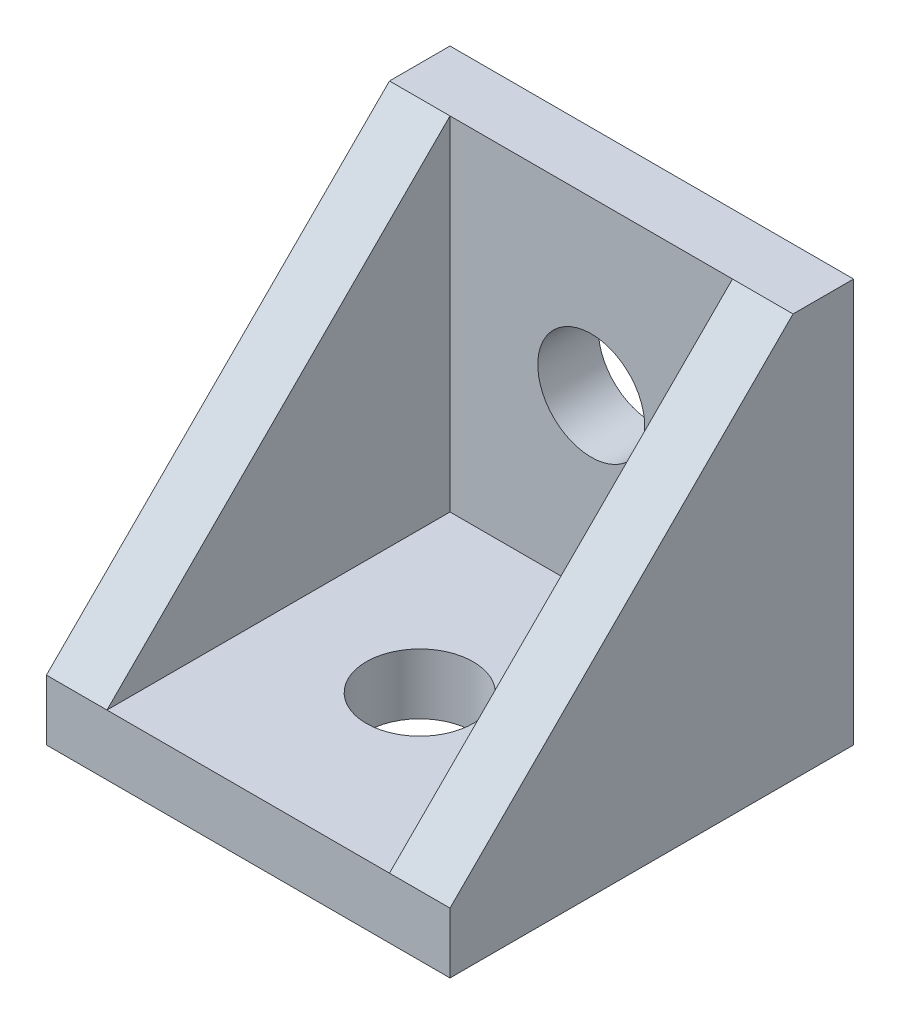
from build123d import *

# Parameters (mm, degrees)
ESBO_O1_W                = 20
ESBO_O1_H                = 20
RESSALTO_EXTRUS_O1_DEPTH = 20
CORTE_EXTRUS_O1_DEPTH    = 21
ESBO_O3_W                = 14
ESBO_O3_H                = 17
CORTE_EXTRUS_O2_DEPTH    = 17
ESBO_O4_W                = 6
ESBO_O4_H                = 6
RESSALTO_EXTRUS_O2_DEPTH = 2
ESBO_O5_W                = 6
ESBO_O5_H                = 6
RESSALTO_EXTRUS_O3_DEPTH = 2
ESBO_O6_R                = 2.65
CORTE_EXTRUS_O3_DEPTH    = 6
ESBO_O7_R                = 2.65
CORTE_EXTRUS_O4_DEPTH    = 6


with BuildPart() as part:
    # Esboço1 → Ressalto-extrusão1 (new body)
    with BuildSketch(Plane.XY):
        with Locations((10, 10)):
            Rectangle(ESBO_O1_W, ESBO_O1_H)
    extrude(amount=RESSALTO_EXTRUS_O1_DEPTH)

    # Esboço2 → Corte-extrusão1 (cut, through all)
    with BuildSketch(Plane(origin=(20, 0, 0), x_dir=(0, 0, -1), z_dir=(1, 0, 0))):
        Polygon((-3, 20), (-20, 3), (-20, 20), align=None)
    extrude(amount=-CORTE_EXTRUS_O1_DEPTH, mode=Mode.SUBTRACT)

    # Esboço3 → Corte-extrusão2 (cut)
    with BuildSketch(Plane.XY.offset(20)):
        with Locations((10, 11.5)):
            Rectangle(ESBO_O3_W, ESBO_O3_H)
    extrude(amount=-CORTE_EXTRUS_O2_DEPTH, mode=Mode.SUBTRACT)

    # Esboço4 → Ressalto-extrusão2 (add)
    with BuildSketch(Plane(origin=(0, 0, 0), x_dir=(-1, 0, 0), z_dir=(0, 0, -1))):
        with Locations((-10, 3)):
            Rectangle(ESBO_O4_W, ESBO_O4_H)
    extrude(amount=RESSALTO_EXTRUS_O2_DEPTH)

    # Esboço5 → Ressalto-extrusão3 (add)
    with BuildSketch(Plane.XZ):
        with Locations((10, 3)):
            Rectangle(ESBO_O5_W, ESBO_O5_H)
    extrude(amount=RESSALTO_EXTRUS_O3_DEPTH)

    # Esboço6 → Corte-extrusão3 (cut, through all)
    with BuildSketch(Plane.XY.offset(3)):
        with Locations((10, 11.5)):
            Circle(ESBO_O6_R)
    extrude(amount=-CORTE_EXTRUS_O3_DEPTH, mode=Mode.SUBTRACT)

    # Esboço7 → Corte-extrusão4 (cut, through all)
    with BuildSketch(Plane(origin=(0, 3, 0), x_dir=(1, 0, 0), z_dir=(0, 1, 0))):
        with Locations((10, -11.5)):
            Circle(ESBO_O7_R)
    extrude(amount=-CORTE_EXTRUS_O4_DEPTH, mode=Mode.SUBTRACT)


solid = part.part
